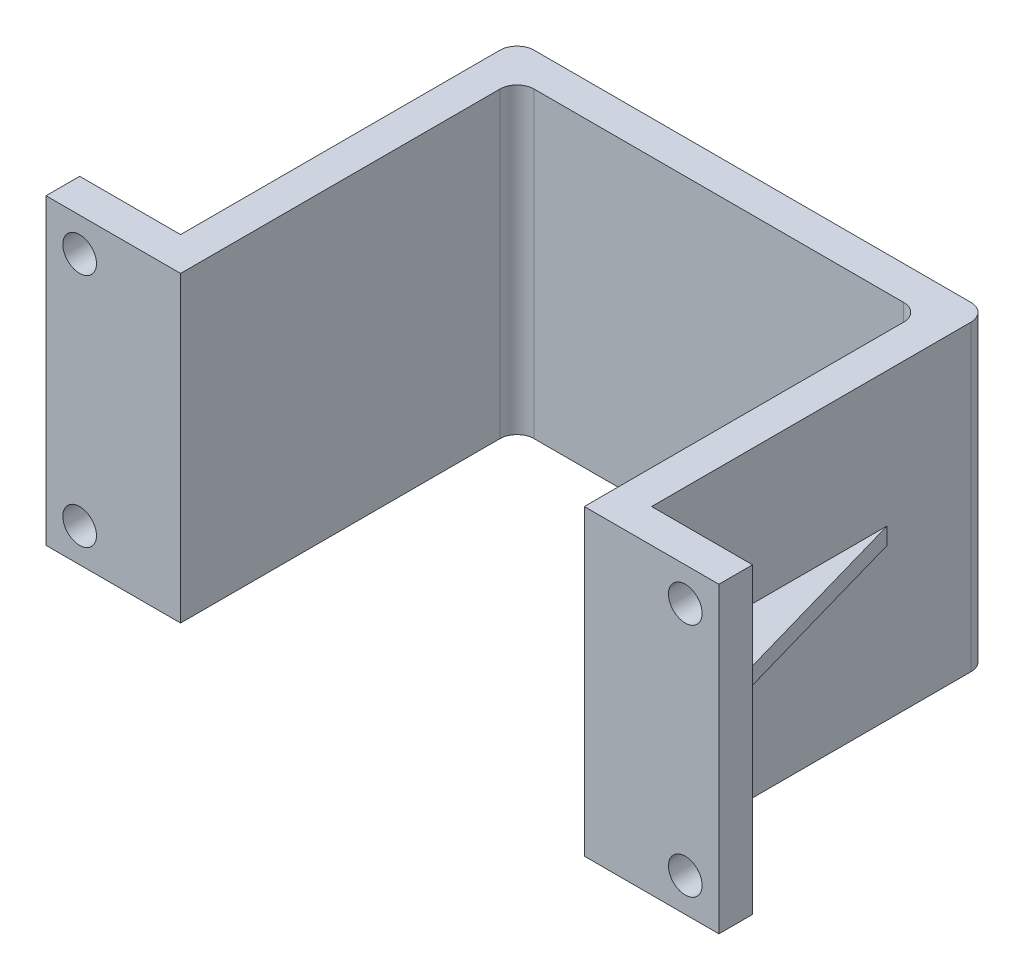
from build123d import *

# Parameters (mm, degrees)
BOSS_EXTRUDE1_DEPTH = 9
SKETCH2_R           = 0.5
CUT_EXTRUDE1_DEPTH  = 9
BOSS_EXTRUDE2_DEPTH = 0.5


with BuildPart() as part:
    # Sketch1 → Boss-Extrude1 (new body)
    with BuildSketch(Plane(origin=(0, 0, 0), x_dir=(1, 0, 0), z_dir=(0, 1, 0))):
        with BuildLine():
            Line((12.508, 0), (14.291457286, 0))
            Line((14.291457286, 0), (16, 0))
            Line((16, 0), (16, 1))
            Line((16, 1), (13.508, 1))
            Line((13.508, 1), (13, 1))
            Line((13, 1), (13, 1.508))
            Line((13, 1.508), (13, 10.492))
            ThreePointArc((13, 10.492), (12.851210245, 10.851210245), (12.492, 11))
            Line((12.492, 11), (-0.492, 11))
            ThreePointArc((-0.492, 11), (-0.851210245, 10.851210245), (-1, 10.492))
            Line((-1, 10.492), (-1, 1.508))
            Line((-1, 1.508), (-1, 1))
            Line((-1, 1), (-1.508, 1))
            Line((-1.508, 1), (-4, 1))
            Line((-4, 1), (-4, 0))
            Line((-4, 0), (-0.904522613, 0))
            Line((-0.904522613, 0), (-0.508, 0))
            Line((-0.508, 0), (0, 0))
            Line((0, 0), (0, 0.508))
            Line((0, 0.508), (0, 9.492))
            ThreePointArc((0, 9.492), (0.148789755, 9.851210245), (0.508, 10))
            Line((0.508, 10), (11.492, 10))
            ThreePointArc((11.492, 10), (11.851210245, 9.851210245), (12, 9.492))
            Line((12, 9.492), (12, 0.508))
            Line((12, 0.508), (12, 0))
            Line((12, 0), (12.508, 0))
        make_face()
    extrude(amount=BOSS_EXTRUDE1_DEPTH)

    # Sketch2 → Cut-Extrude1 (cut)
    with BuildSketch(Plane(origin=(0, 0, -1), x_dir=(-1, 0, 0), z_dir=(0, 0, -1))):
        with Locations((3, 1)):
            Circle(SKETCH2_R)
        with Locations((3, 8)):
            Circle(SKETCH2_R)
        with Locations((-15, 1)):
            Circle(SKETCH2_R)
        with Locations((-15, 8)):
            Circle(SKETCH2_R)
    extrude(amount=-CUT_EXTRUDE1_DEPTH, mode=Mode.SUBTRACT)

    # Sketch3 → Boss-Extrude2 (add)
    with BuildSketch(Plane(origin=(0, 4.50000011, 0), x_dir=(1, 0, 0), z_dir=(0, 1, 0))):
        Polygon((-3, 1), (-1, 8), (-1, 1), align=None)
        Polygon((13, 8), (13, 1), (15, 1), align=None)
    extrude(amount=BOSS_EXTRUDE2_DEPTH)


solid = part.part
